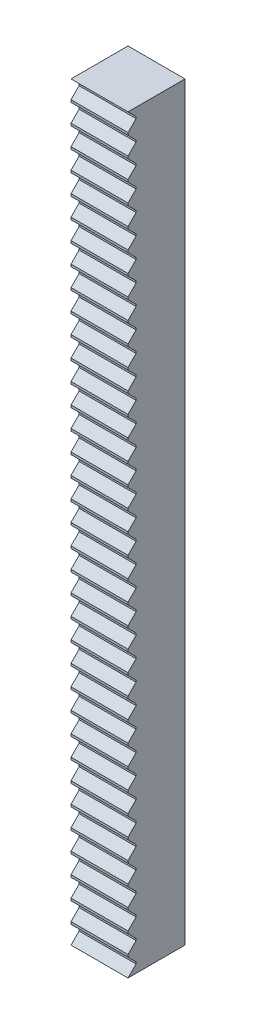
from build123d import *

# Parameters (mm, degrees)
SKETCH1_W           = 19
SKETCH1_H           = 250
BOSS_EXTRUDE1_DEPTH = 9.5
CUT_EXTRUDE1_DEPTH  = 29


with BuildPart() as part:
    # Sketch1 → Boss-Extrude1 (new body, symmetric)
    with BuildSketch(Plane.XY):
        Rectangle(SKETCH1_W, SKETCH1_H)
    extrude(amount=BOSS_EXTRUDE1_DEPTH, both=True)

    # Sketch2 → Cut-Extrude1 (cut)
    with BuildSketch(Plane.ZY.offset(9.5)):
        Polygon((9.5, 125), (6.8, 122.3), (6.8, 121.7), (9.5, 119), (10.5, 119), (10.5, 125), align=None)
        Polygon((9.5, 118.222222222), (6.8, 115.522222222), (6.8, 114.922222222), (9.5, 112.222222222), (10.5, 112.222222222), (10.5, 118.222222222), align=None)
        Polygon((9.5, 111.444444444), (6.8, 108.744444444), (6.8, 108.144444444), (9.5, 105.444444444), (10.5, 105.444444444), (10.5, 111.444444444), align=None)
        Polygon((9.5, 104.666666667), (6.8, 101.966666667), (6.8, 101.366666667), (9.5, 98.666666667), (10.5, 98.666666667), (10.5, 104.666666667), align=None)
        Polygon((9.5, 97.888888889), (6.8, 95.188888889), (6.8, 94.588888889), (9.5, 91.888888889), (10.5, 91.888888889), (10.5, 97.888888889), align=None)
        Polygon((9.5, 91.111111111), (6.8, 88.411111111), (6.8, 87.811111111), (9.5, 85.111111111), (10.5, 85.111111111), (10.5, 91.111111111), align=None)
        Polygon((9.5, 84.333333333), (6.8, 81.633333333), (6.8, 81.033333333), (9.5, 78.333333333), (10.5, 78.333333333), (10.5, 84.333333333), align=None)
        Polygon((9.5, 77.555555556), (6.8, 74.855555556), (6.8, 74.255555556), (9.5, 71.555555556), (10.5, 71.555555556), (10.5, 77.555555556), align=None)
        Polygon((9.5, 70.777777778), (6.8, 68.077777778), (6.8, 67.477777778), (9.5, 64.777777778), (10.5, 64.777777778), (10.5, 70.777777778), align=None)
        Polygon((9.5, 64), (6.8, 61.3), (6.8, 60.7), (9.5, 58), (10.5, 58), (10.5, 64), align=None)
        Polygon((9.5, 57.222222222), (6.8, 54.522222222), (6.8, 53.922222222), (9.5, 51.222222222), (10.5, 51.222222222), (10.5, 57.222222222), align=None)
        Polygon((9.5, 50.444444444), (6.8, 47.744444444), (6.8, 47.144444444), (9.5, 44.444444444), (10.5, 44.444444444), (10.5, 50.444444444), align=None)
        Polygon((9.5, 43.666666667), (6.8, 40.966666667), (6.8, 40.366666667), (9.5, 37.666666667), (10.5, 37.666666667), (10.5, 43.666666667), align=None)
        Polygon((9.5, 36.888888889), (6.8, 34.188888889), (6.8, 33.588888889), (9.5, 30.888888889), (10.5, 30.888888889), (10.5, 36.888888889), align=None)
        Polygon((9.5, 30.111111111), (6.8, 27.411111111), (6.8, 26.811111111), (9.5, 24.111111111), (10.5, 24.111111111), (10.5, 30.111111111), align=None)
        Polygon((9.5, 23.333333333), (6.8, 20.633333333), (6.8, 20.033333333), (9.5, 17.333333333), (10.5, 17.333333333), (10.5, 23.333333333), align=None)
        Polygon((9.5, 16.555555556), (6.8, 13.855555556), (6.8, 13.255555556), (9.5, 10.555555556), (10.5, 10.555555556), (10.5, 16.555555556), align=None)
        Polygon((9.5, 9.777777778), (6.8, 7.077777778), (6.8, 6.477777778), (9.5, 3.777777778), (10.5, 3.777777778), (10.5, 9.777777778), align=None)
        Polygon((9.5, 3), (6.8, 0.3), (6.8, -0.3), (9.5, -3), (10.5, -3), (10.5, 3), align=None)
        Polygon((9.5, -3.777777778), (6.8, -6.477777778), (6.8, -7.077777778), (9.5, -9.777777778), (10.5, -9.777777778), (10.5, -3.777777778), align=None)
        Polygon((9.5, -10.555555556), (6.8, -13.255555556), (6.8, -13.855555556), (9.5, -16.555555556), (10.5, -16.555555556), (10.5, -10.555555556), align=None)
        Polygon((9.5, -17.333333333), (6.8, -20.033333333), (6.8, -20.633333333), (9.5, -23.333333333), (10.5, -23.333333333), (10.5, -17.333333333), align=None)
        Polygon((9.5, -24.111111111), (6.8, -26.811111111), (6.8, -27.411111111), (9.5, -30.111111111), (10.5, -30.111111111), (10.5, -24.111111111), align=None)
        Polygon((9.5, -30.888888889), (6.8, -33.588888889), (6.8, -34.188888889), (9.5, -36.888888889), (10.5, -36.888888889), (10.5, -30.888888889), align=None)
        Polygon((9.5, -37.666666667), (6.8, -40.366666667), (6.8, -40.966666667), (9.5, -43.666666667), (10.5, -43.666666667), (10.5, -37.666666667), align=None)
        Polygon((9.5, -44.444444444), (6.8, -47.144444444), (6.8, -47.744444444), (9.5, -50.444444444), (10.5, -50.444444444), (10.5, -44.444444444), align=None)
        Polygon((9.5, -51.222222222), (6.8, -53.922222222), (6.8, -54.522222222), (9.5, -57.222222222), (10.5, -57.222222222), (10.5, -51.222222222), align=None)
        Polygon((9.5, -58), (6.8, -60.7), (6.8, -61.3), (9.5, -64), (10.5, -64), (10.5, -58), align=None)
        Polygon((9.5, -64.777777778), (6.8, -67.477777778), (6.8, -68.077777778), (9.5, -70.777777778), (10.5, -70.777777778), (10.5, -64.777777778), align=None)
        Polygon((9.5, -71.555555556), (6.8, -74.255555556), (6.8, -74.855555556), (9.5, -77.555555556), (10.5, -77.555555556), (10.5, -71.555555556), align=None)
        Polygon((9.5, -78.333333333), (6.8, -81.033333333), (6.8, -81.633333333), (9.5, -84.333333333), (10.5, -84.333333333), (10.5, -78.333333333), align=None)
        Polygon((9.5, -85.111111111), (6.8, -87.811111111), (6.8, -88.411111111), (9.5, -91.111111111), (10.5, -91.111111111), (10.5, -85.111111111), align=None)
        Polygon((9.5, -91.888888889), (6.8, -94.588888889), (6.8, -95.188888889), (9.5, -97.888888889), (10.5, -97.888888889), (10.5, -91.888888889), align=None)
        Polygon((9.5, -98.666666667), (6.8, -101.366666667), (6.8, -101.966666667), (9.5, -104.666666667), (10.5, -104.666666667), (10.5, -98.666666667), align=None)
        Polygon((9.5, -105.444444444), (6.8, -108.144444444), (6.8, -108.744444444), (9.5, -111.444444444), (10.5, -111.444444444), (10.5, -105.444444444), align=None)
        Polygon((9.5, -112.222222222), (6.8, -114.922222222), (6.8, -115.522222222), (9.5, -118.222222222), (10.5, -118.222222222), (10.5, -112.222222222), align=None)
        Polygon((9.5, -119), (6.8, -121.7), (6.8, -122.3), (9.5, -125), (10.5, -125), (10.5, -119), align=None)
    extrude(amount=-CUT_EXTRUDE1_DEPTH, mode=Mode.SUBTRACT)


solid = part.part
